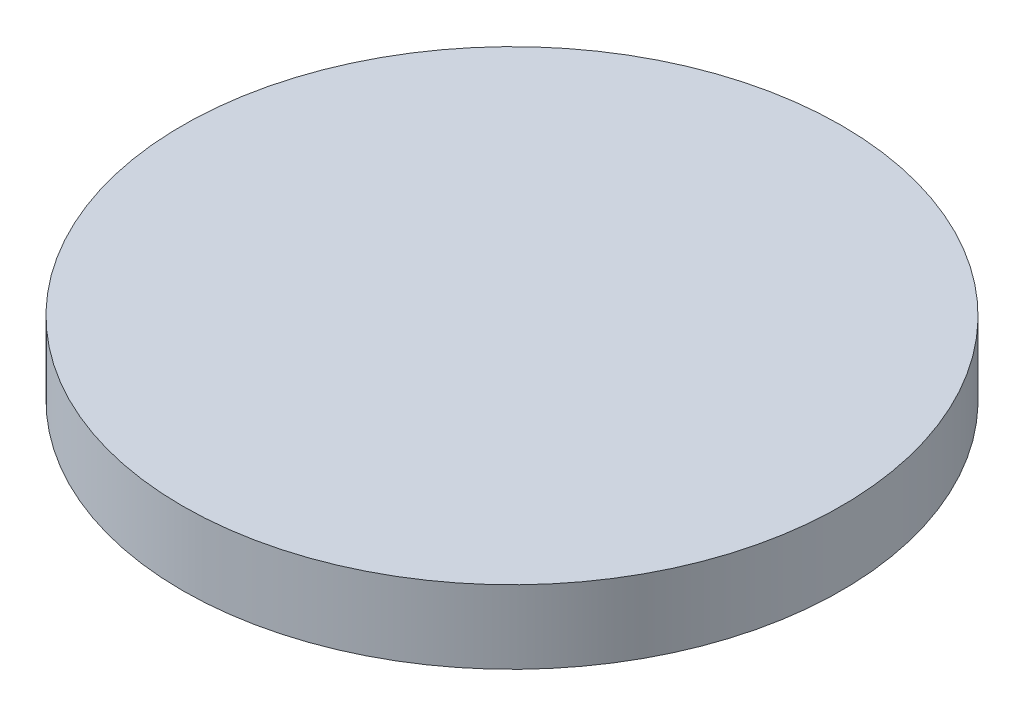
from build123d import *

# Parameters (mm, degrees)
SKETCH1_R           = 45
BOSS_EXTRUDE1_DEPTH = 10


with BuildPart() as part:
    # Sketch1 → Boss-Extrude1 (new body)
    with BuildSketch(Plane(origin=(0, 0, 0), x_dir=(1, 0, 0), z_dir=(0, 1, 0))):
        Circle(SKETCH1_R)
    extrude(amount=BOSS_EXTRUDE1_DEPTH)


solid = part.part
